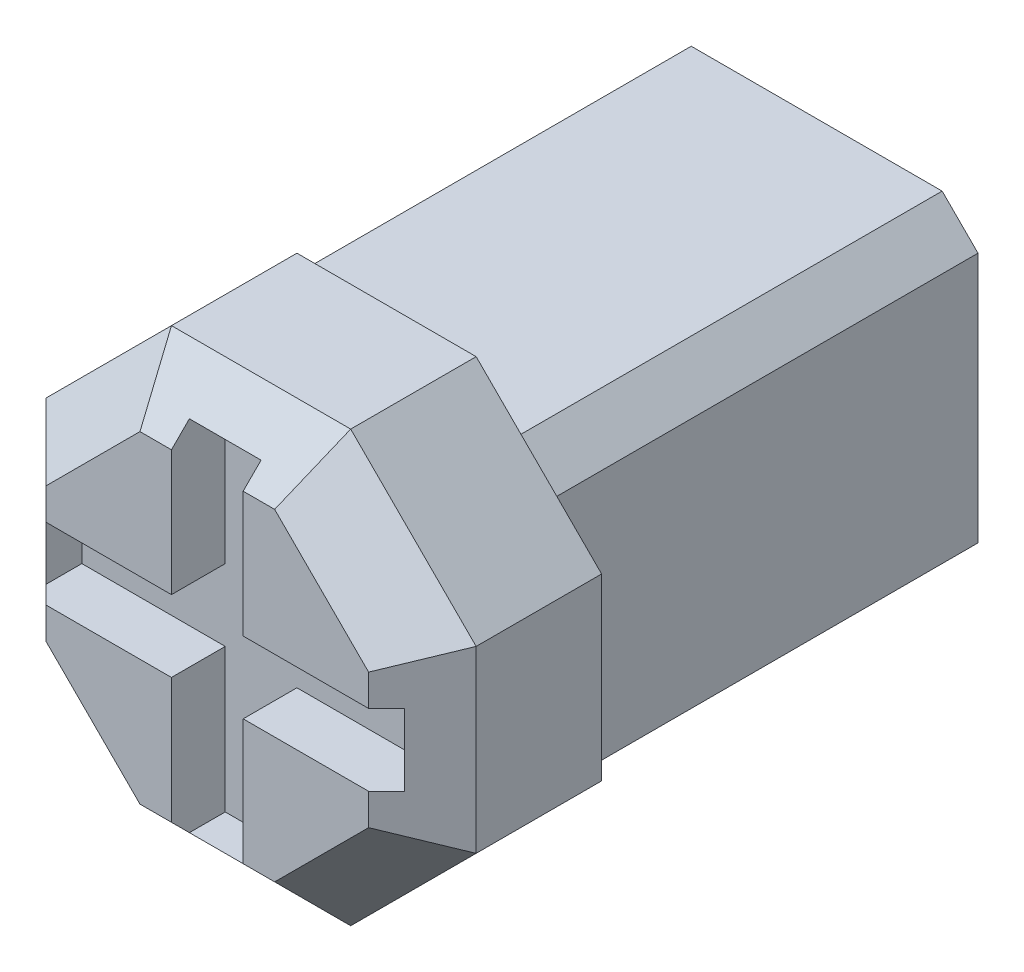
from build123d import *

# Parameters (mm, degrees)
ESQUISSE1_W             = 9
ESQUISSE1_H             = 9
EXTRUSION1_DEPTH        = 12
ESQUISSE2_W             = 12
ESQUISSE2_H             = 12
EXTRUSION2_DEPTH        = 5
CHANFREIN3_SIZE         = 1
CHANFREIN1_SIZE         = 3.5
CHANFREIN2_SIZE         = 1.5
ESQUISSE3_W             = 2
ESQUISSE3_H             = 3.5
ESQUISSE3_W_2           = 3.5
ESQUISSE3_H_2           = 2
ESQUISSE3_W_3           = 0.5
ESQUISSE3_H_3           = 0.5
ENL_V_MAT_EXTRU_1_DEPTH = 1.5


with BuildPart() as part:
    # Esquisse1 → Extrusion1 (new body)
    with BuildSketch(Plane.XY):
        Rectangle(ESQUISSE1_W, ESQUISSE1_H)
    extrude(amount=EXTRUSION1_DEPTH)

    # Esquisse2 → Extrusion2 (add)
    with BuildSketch(Plane.XY.offset(12)):
        Rectangle(ESQUISSE2_W, ESQUISSE2_H)
    extrude(amount=EXTRUSION2_DEPTH)

    # Chanfrein3
    chanfrein3_edges = [part.edges().sort_by_distance(p)[0] for p in [
        (-4.5, 4.5, 6),
        (4.5, 4.5, 6),
        (4.5, -4.5, 6),
        (-4.5, -4.5, 6),
    ]]
    chamfer(chanfrein3_edges, length=CHANFREIN3_SIZE)

    # Chanfrein1
    chanfrein1_edges = [part.edges().sort_by_distance(p)[0] for p in [
        (6, 6, 14.5),
        (-6, 6, 14.5),
        (-6, -6, 14.5),
        (6, -6, 14.5),
    ]]
    chamfer(chanfrein1_edges, length=CHANFREIN1_SIZE)

    # Chanfrein2
    chanfrein2_edges = [part.edges().sort_by_distance(p)[0] for p in [
        (0, 6, 17),
        (6, 0, 17),
        (-6, 0, 17),
        (0, -6, 17),
        (-4.25, 4.25, 17),
        (-4.25, -4.25, 17),
        (4.25, -4.25, 17),
        (4.25, 4.25, 17),
    ]]
    chamfer(chanfrein2_edges, length=CHANFREIN2_SIZE)

    # Esquisse3 → Enlèv. mat.-Extru.1 (cut)
    with BuildSketch(Plane.XY.offset(17)):
        with Locations((0, 2.75)):
            Rectangle(ESQUISSE3_W, ESQUISSE3_H)
        with Locations((-2.75, 0)):
            Rectangle(ESQUISSE3_W_2, ESQUISSE3_H_2)
        Rectangle(ESQUISSE3_W, ESQUISSE3_H_2)
        with Locations((0, -2.75)):
            Rectangle(ESQUISSE3_W, ESQUISSE3_H)
        with Locations((2.75, 0)):
            Rectangle(ESQUISSE3_W_2, ESQUISSE3_H_2)
        with Locations((-4.75, 0)):
            Rectangle(ESQUISSE3_W_3, ESQUISSE3_H_2)
        with Locations((0, 4.75)):
            Rectangle(ESQUISSE3_W, ESQUISSE3_H_3)
        with Locations((0, -4.75)):
            Rectangle(ESQUISSE3_W, ESQUISSE3_H_3)
        with Locations((4.75, 0)):
            Rectangle(ESQUISSE3_W_3, ESQUISSE3_H_2)
    extrude(amount=-ENL_V_MAT_EXTRU_1_DEPTH, mode=Mode.SUBTRACT)


solid = part.part
